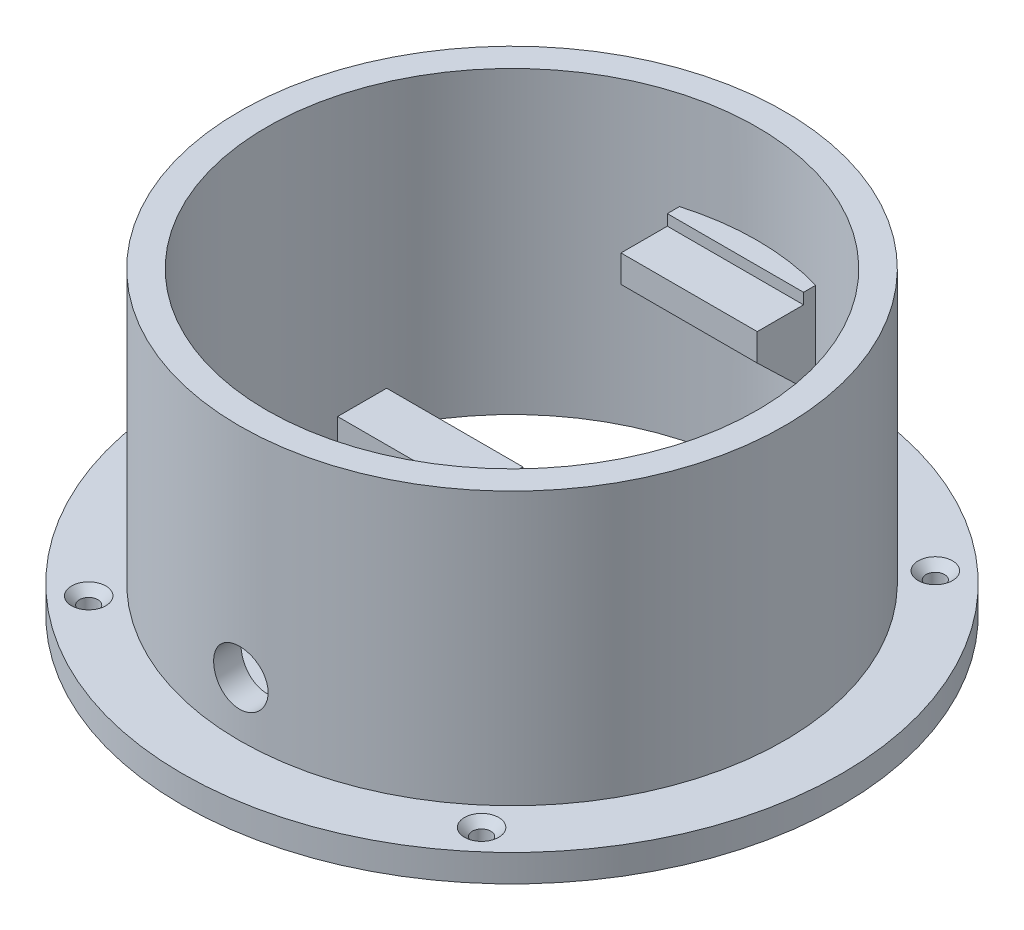
from build123d import *

# Parameters (mm, degrees)
SKETCH1_R                                       = 60.5
BOSS_EXTRUDE1_DEPTH                             = 5
SKETCH2_R                                       = 50
SKETCH2_R_2                                     = 45
BOSS_EXTRUDE2_DEPTH                             = 50
SKETCH3_W                                       = 9
SKETCH3_H                                       = 9
BOSS_EXTRUDE3_DEPTH                             = 1
SKETCH3_3_W                                     = 8
SKETCH3_3_H                                     = 9
BOSS_EXTRUDE4_DEPTH                             = 25
SKETCH4_W                                       = 25
SKETCH4_H                                       = 9
BOSS_EXTRUDE5_DEPTH                             = 5
BOSS_EXTRUDE7_DEPTH                             = 12.5
CSK_FOR_M3_FLAT_HEAD_MACHINE_SCREW1_D           = 3.4
CSK_FOR_M3_FLAT_HEAD_MACHINE_SCREW1_DEPTH       = 5
CSK_FOR_M3_FLAT_HEAD_MACHINE_SCREW1_CSINK_D     = 6.3
CSK_FOR_M3_FLAT_HEAD_MACHINE_SCREW1_CSINK_ANGLE = 90
CUT_EXTRUDE1_REACH                              = 132
SKETCH10_R                                      = 5


with BuildPart() as part:
    # Sketch1 → Boss-Extrude1 (new body)
    with BuildSketch(Plane(origin=(0, 0, 0), x_dir=(1, 0, 0), z_dir=(0, 1, 0))):
        Circle(SKETCH1_R)
        with BuildLine():
            Line((-14, -10.5), (14, -10.5))
            Line((14, -10.5), (35.078449216, -28.186918963))
            ThreePointArc((35.078449216, -28.186918963), (0, 45), (-35.078449216, -28.186918963))
            Line((-35.078449216, -28.186918963), (-14, -10.5))
        make_face(mode=Mode.SUBTRACT)
        with BuildLine():
            Line((-17.5, -23.5), (-23.628355545, -28.642300877))
            ThreePointArc((-23.628355545, -28.642300877), (0, -36.5), (23.628355545, -28.642300877))
            Line((23.628355545, -28.642300877), (17.5, -23.5))
            Line((17.5, -23.5), (-17.5, -23.5))
        make_face(mode=Mode.SUBTRACT)
    extrude(amount=BOSS_EXTRUDE1_DEPTH)

    # Sketch2 → Boss-Extrude2 (add)
    with BuildSketch(Plane(origin=(0, 5, 0), x_dir=(1, 0, 0), z_dir=(0, 1, 0))):
        Circle(SKETCH2_R)
        Circle(SKETCH2_R_2, mode=Mode.SUBTRACT)
    extrude(amount=BOSS_EXTRUDE2_DEPTH)

    # Sketch3 → Boss-Extrude3 (add)
    with BuildSketch(Plane(origin=(0, 5, 0), x_dir=(1, 0, 0), z_dir=(0, 1, 0))):
        with Locations((0, -15)):
            Rectangle(SKETCH3_W, SKETCH3_H)
    extrude(amount=BOSS_EXTRUDE3_DEPTH)

    # Sketch3_3 → Boss-Extrude4 (add)
    with BuildSketch(Plane(origin=(0, 5, 0), x_dir=(1, 0, 0), z_dir=(0, 1, 0))):
        with Locations((-8.5, -15)):
            Rectangle(SKETCH3_3_W, SKETCH3_3_H)
        with Locations((8.5, -15)):
            Rectangle(SKETCH3_3_W, SKETCH3_3_H)
    extrude(amount=BOSS_EXTRUDE4_DEPTH)

    # Sketch4 → Boss-Extrude5 (add)
    with BuildSketch(Plane(origin=(0, 30, 0), x_dir=(1, 0, 0), z_dir=(0, 1, 0))):
        with Locations((0, -15)):
            Rectangle(SKETCH4_W, SKETCH4_H)
    extrude(amount=BOSS_EXTRUDE5_DEPTH)

    # Sketch5 → Boss-Extrude7 (add, symmetric)
    with BuildSketch(Plane(origin=(0, 0, 0), x_dir=(0, 0, -1), z_dir=(1, 0, 0))):
        Polygon((41, 35), (32.5, 35), (32.5, 30), (46, 17), (46, 37), (41, 37), align=None)
    extrude(amount=BOSS_EXTRUDE7_DEPTH, both=True)

    # CSK for M3 Flat Head Machine Screw1
    with Locations(Plane(origin=(0, 5, 0), x_dir=(1, 0, 0), z_dir=(0, 1, 0))):
        with Locations((-36.842001616, 40.837077723), (36.842001616, 40.837077723), (36, -41.581245773), (-36.842001616, -40.837077723)):
            CounterSinkHole(CSK_FOR_M3_FLAT_HEAD_MACHINE_SCREW1_D / 2, CSK_FOR_M3_FLAT_HEAD_MACHINE_SCREW1_CSINK_D / 2, depth=CSK_FOR_M3_FLAT_HEAD_MACHINE_SCREW1_DEPTH, counter_sink_angle=CSK_FOR_M3_FLAT_HEAD_MACHINE_SCREW1_CSINK_ANGLE)

    # Sketch10 → Cut-Extrude1 (cut, up to next)
    with BuildSketch(Plane.XY.offset(69.5), mode=Mode.PRIVATE) as cut_extrude1_sk1:
        with Locations((0, 15)):
            Circle(SKETCH10_R)
    cut_extrude1_tool1 = extrude(cut_extrude1_sk1.sketch, amount=-CUT_EXTRUDE1_REACH, mode=Mode.PRIVATE) & part.part
    add(cut_extrude1_tool1.solids().sort_by_distance((0, 15, 69.5))[0], mode=Mode.SUBTRACT)


solid = part.part
